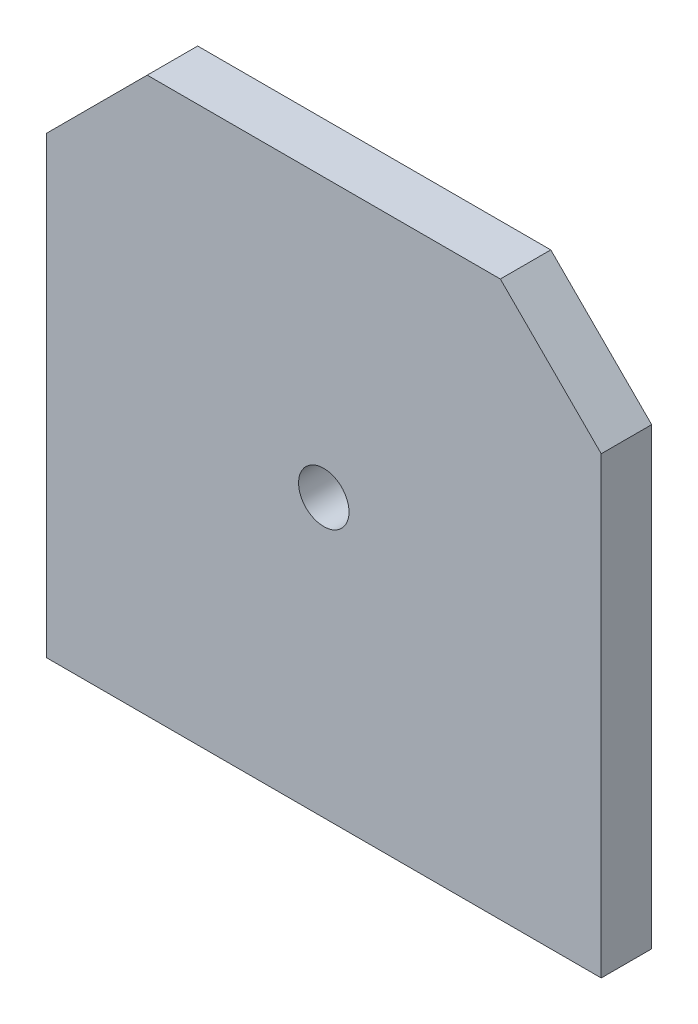
from build123d import *

# Parameters (mm, degrees)
SKETCH1_R           = 2.5
BOSS_EXTRUDE1_DEPTH = 5


with BuildPart() as part:
    # Sketch1 → Boss-Extrude1 (new body)
    with BuildSketch(Plane.XY):
        Polygon((-27.5, 17.5), (-17.5, 27.5), (17.5, 27.5), (27.5, 17.5), (27.5, -27.5), (-27.5, -27.5), align=None)
        Circle(SKETCH1_R, mode=Mode.SUBTRACT)
    extrude(amount=BOSS_EXTRUDE1_DEPTH)


solid = part.part
